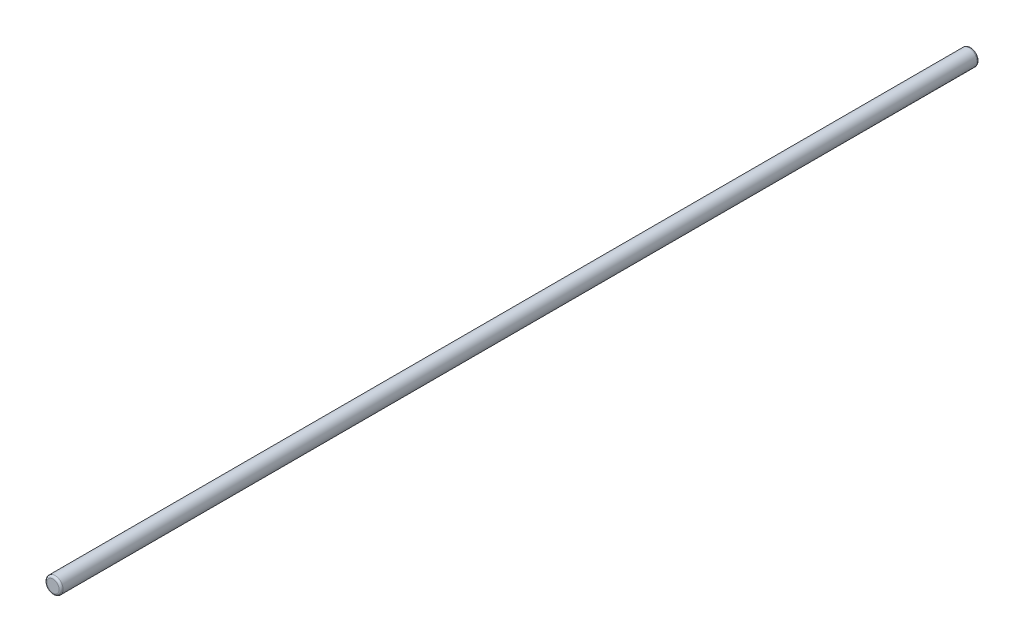
from build123d import *

# Parameters (mm, degrees)
EXTRUDE2_DEPTH      = 225
EXTRUDE2_DEPTH_BACK = 225
SKETCH1_R           = 4
FILLET2_R           = 1
FILLET3_R           = 1


with BuildPart() as part:
    # Sketch1 → Extrude2 (new, two sides: drawn at the far end of the back side and taken through both)
    with BuildSketch(Plane.XY.offset(-EXTRUDE2_DEPTH_BACK)):
        Circle(SKETCH1_R)
    extrude(amount=EXTRUDE2_DEPTH + EXTRUDE2_DEPTH_BACK)

    # Fillet2
    fillet2_edges = [part.edges().sort_by_distance(p)[0] for p in [
        (-4, 0, -225),
    ]]
    fillet(fillet2_edges, radius=FILLET2_R)

    # Fillet3
    fillet3_edges = [part.edges().sort_by_distance(p)[0] for p in [
        (-4, 0, 225),
    ]]
    fillet(fillet3_edges, radius=FILLET3_R)


solid = part.part
